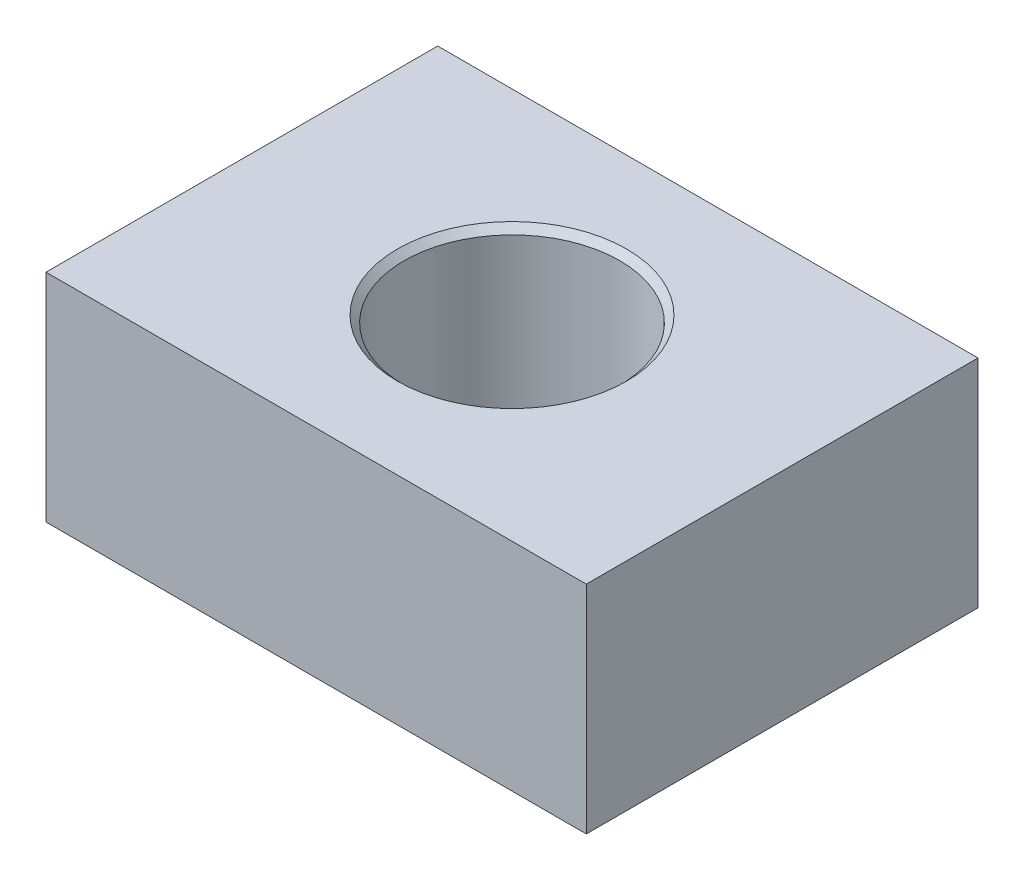
from build123d import *

# Parameters (mm, degrees)
SKETCH1_W      = 20
SKETCH1_H      = 14.5
SKETCH1_R      = 3.99
EXTRUDE1_DEPTH = 8.01
CHAMFER1_SIZE  = 0.25


with BuildPart() as part:
    # Sketch1 → Extrude1 (new body)
    with BuildSketch(Plane(origin=(0, 0, 0), x_dir=(1, 0, 0), z_dir=(0, 1, 0))):
        Rectangle(SKETCH1_W, SKETCH1_H)
        with Locations(Location((0, 0, 0), (0, 0, 270))):  # turned: the seam where the file's is
            Circle(SKETCH1_R, mode=Mode.SUBTRACT)
    extrude(amount=EXTRUDE1_DEPTH)

    # Chamfer1
    chamfer1_edges = [part.edges().sort_by_distance(p)[0] for p in [
        (0, 0, -3.99),
        (0, 8.01, -3.99),
    ]]
    chamfer(chamfer1_edges, length=CHAMFER1_SIZE)


solid = part.part
